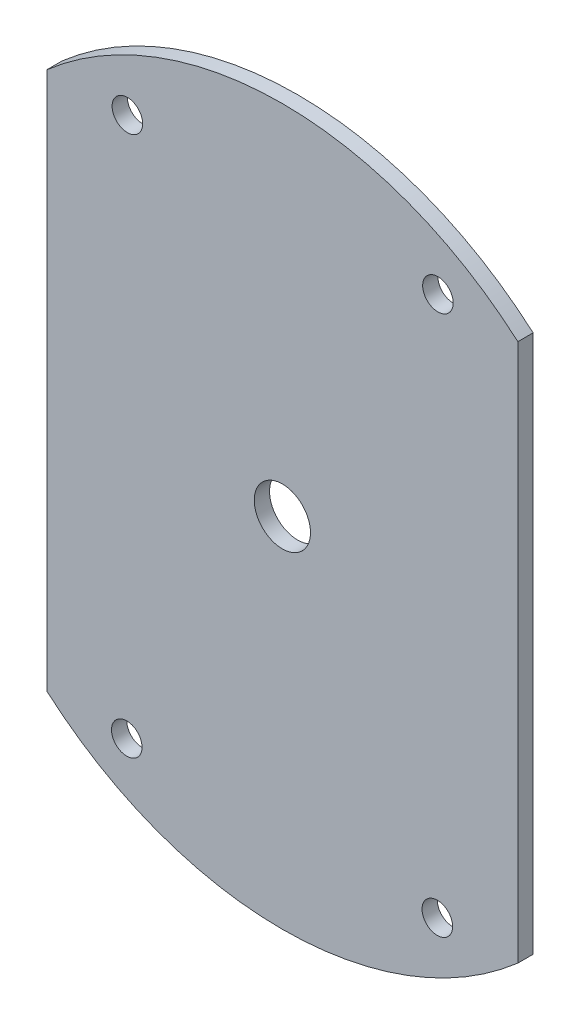
from build123d import *

# Parameters (mm, degrees)
SKETCH3_R           = 74.295
SKETCH3_R_2         = 3.175
SKETCH3_R_3         = 5.842
BOSS_EXTRUDE2_DEPTH = 3.175
CUT_EXTRUDE2_DEPTH  = 4.175


with BuildPart() as part:
    # Sketch3 → Boss-Extrude2 (new body)
    with BuildSketch(Plane.XY):
        Circle(SKETCH3_R)
        with Locations((-32.198217622, 56.128319663)):
            Circle(SKETCH3_R_2, mode=Mode.SUBTRACT)
        with Locations((32.322739207, 56.128319663)):
            Circle(SKETCH3_R_2, mode=Mode.SUBTRACT)
        with Locations((-32.322739207, -56.128319663)):
            Circle(SKETCH3_R_2, mode=Mode.SUBTRACT)
        with Locations((32.198217622, -56.128319663)):
            Circle(SKETCH3_R_2, mode=Mode.SUBTRACT)
        Circle(SKETCH3_R_3, mode=Mode.SUBTRACT)
    extrude(amount=BOSS_EXTRUDE2_DEPTH)

    # Sketch4 → Cut-Extrude2 (cut, through all)
    with BuildSketch(Plane.XY.offset(3.175)):
        with BuildLine():
            Line((-48.930202294, 55.906907699), (-48.930202294, -55.906907699))
            ThreePointArc((-48.930202294, -55.906907699), (-74.295, 0), (-48.930202294, 55.906907699))
        make_face()
        with BuildLine():
            Line((48.930202294, 55.906907699), (48.930202294, -55.906907699))
            ThreePointArc((48.930202294, -55.906907699), (74.295, 0), (48.930202294, 55.906907699))
        make_face()
    extrude(amount=-CUT_EXTRUDE2_DEPTH, mode=Mode.SUBTRACT)


solid = part.part
